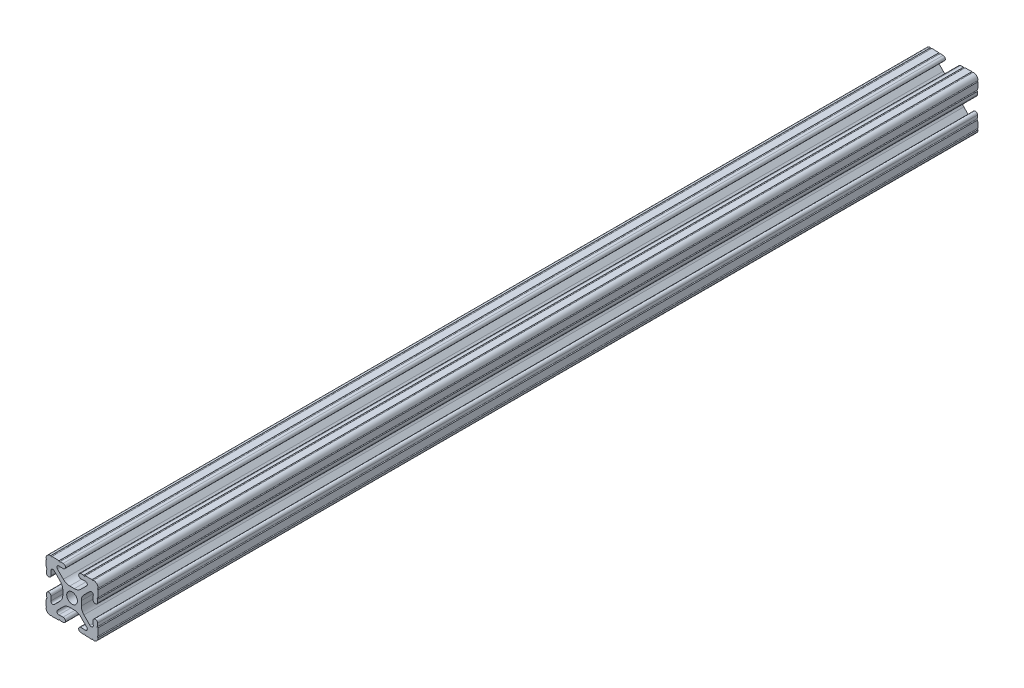
from build123d import *

# Parameters (mm, degrees)
SKETCH3_R      = 2.6035
EXTRUDE1_DEPTH = 214.55


with BuildPart() as part:
    # Sketch3 → Extrude1 (new body, symmetric)
    with BuildSketch(Plane.XY):
        with BuildLine():
            Line((-1.115277175, 4.5085), (1.115277175, 4.5085))
            ThreePointArc((1.115277175, 4.5085), (2.806584872, 4.844922018), (4.240406305, 5.80297087))
            Line((4.240406305, 5.80297087), (7.148423664, 8.710988229))
            ThreePointArc((7.148423664, 8.710988229), (7.349906316, 9.772227925), (6.436353897, 10.348636575))
            Line((6.436353897, 10.348636575), (4.381960454, 10.276895575))
            ThreePointArc((4.381960454, 10.276895575), (3.239173075, 11.342562046), (4.304839546, 12.485349424))
            Line((4.304839546, 12.485349424), (5.728246175, 12.535055879))
            ThreePointArc((5.728246175, 12.535055879), (6.054756855, 12.230579745), (6.35923299, 12.557090424))
            Line((6.35923299, 12.557090424), (9.782092278, 12.676619304))
            ThreePointArc((9.782092278, 12.676619304), (10.108602958, 12.37214317), (10.413079092, 12.69865385))
            ThreePointArc((10.413079092, 12.69865385), (12.052764565, 12.052764565), (12.69865385, 10.413079092))
            ThreePointArc((12.69865385, 10.413079092), (12.37214317, 10.108602958), (12.676619304, 9.782092278))
            Line((12.676619304, 9.782092278), (12.557090424, 6.35923299))
            ThreePointArc((12.557090424, 6.35923299), (12.230579745, 6.054756855), (12.535055879, 5.728246175))
            Line((12.535055879, 5.728246175), (12.485349424, 4.304839546))
            ThreePointArc((12.485349424, 4.304839546), (11.342562046, 3.239173075), (10.276895575, 4.381960454))
            Line((10.276895575, 4.381960454), (10.348636575, 6.436353897))
            ThreePointArc((10.348636575, 6.436353897), (9.772227925, 7.349906316), (8.710988229, 7.148423664))
            Line((8.710988229, 7.148423664), (5.80297087, 4.240406305))
            ThreePointArc((5.80297087, 4.240406305), (4.844922018, 2.806584872), (4.5085, 1.115277175))
            Line((4.5085, 1.115277175), (4.5085, -1.115277175))
            ThreePointArc((4.5085, -1.115277175), (4.844922018, -2.806584872), (5.80297087, -4.240406305))
            Line((5.80297087, -4.240406305), (8.710988229, -7.148423664))
            ThreePointArc((8.710988229, -7.148423664), (9.772227925, -7.349906316), (10.348636575, -6.436353897))
            Line((10.348636575, -6.436353897), (10.276895575, -4.381960454))
            ThreePointArc((10.276895575, -4.381960454), (11.342562046, -3.239173075), (12.485349424, -4.304839546))
            Line((12.485349424, -4.304839546), (12.535055879, -5.728246175))
            ThreePointArc((12.535055879, -5.728246175), (12.230579745, -6.054756855), (12.557090424, -6.35923299))
            Line((12.557090424, -6.35923299), (12.676619304, -9.782092278))
            ThreePointArc((12.676619304, -9.782092278), (12.37214317, -10.108602958), (12.69865385, -10.413079092))
            ThreePointArc((12.69865385, -10.413079092), (12.052764565, -12.052764565), (10.413079092, -12.69865385))
            ThreePointArc((10.413079092, -12.69865385), (10.108602958, -12.37214317), (9.782092278, -12.676619304))
            Line((9.782092278, -12.676619304), (6.35923299, -12.557090424))
            ThreePointArc((6.35923299, -12.557090424), (6.054756855, -12.230579745), (5.728246175, -12.535055879))
            Line((5.728246175, -12.535055879), (4.304839546, -12.485349424))
            ThreePointArc((4.304839546, -12.485349424), (3.239173075, -11.342562046), (4.381960454, -10.276895575))
            Line((4.381960454, -10.276895575), (6.436353897, -10.348636575))
            ThreePointArc((6.436353897, -10.348636575), (7.349906316, -9.772227925), (7.148423664, -8.710988229))
            Line((7.148423664, -8.710988229), (4.240406305, -5.80297087))
            ThreePointArc((4.240406305, -5.80297087), (2.806584872, -4.844922018), (1.115277175, -4.5085))
            Line((1.115277175, -4.5085), (-1.115277175, -4.5085))
            ThreePointArc((-1.115277175, -4.5085), (-2.806584872, -4.844922018), (-4.240406305, -5.80297087))
            Line((-4.240406305, -5.80297087), (-7.148423664, -8.710988229))
            ThreePointArc((-7.148423664, -8.710988229), (-7.349906316, -9.772227925), (-6.436353897, -10.348636575))
            Line((-6.436353897, -10.348636575), (-4.381960454, -10.276895575))
            ThreePointArc((-4.381960454, -10.276895575), (-3.239173075, -11.342562046), (-4.304839546, -12.485349424))
            Line((-4.304839546, -12.485349424), (-5.728246175, -12.535055879))
            ThreePointArc((-5.728246175, -12.535055879), (-6.054756855, -12.230579745), (-6.35923299, -12.557090424))
            Line((-6.35923299, -12.557090424), (-9.782092278, -12.676619304))
            ThreePointArc((-9.782092278, -12.676619304), (-10.108602958, -12.37214317), (-10.413079092, -12.69865385))
            ThreePointArc((-10.413079092, -12.69865385), (-12.052764565, -12.052764565), (-12.69865385, -10.413079092))
            ThreePointArc((-12.69865385, -10.413079092), (-12.37214317, -10.108602958), (-12.676619304, -9.782092278))
            Line((-12.676619304, -9.782092278), (-12.557090424, -6.35923299))
            ThreePointArc((-12.557090424, -6.35923299), (-12.230579745, -6.054756855), (-12.535055879, -5.728246175))
            Line((-12.535055879, -5.728246175), (-12.485349424, -4.304839546))
            ThreePointArc((-12.485349424, -4.304839546), (-11.342562046, -3.239173075), (-10.276895575, -4.381960454))
            Line((-10.276895575, -4.381960454), (-10.348636575, -6.436353897))
            ThreePointArc((-10.348636575, -6.436353897), (-9.772227925, -7.349906316), (-8.710988229, -7.148423664))
            Line((-8.710988229, -7.148423664), (-5.80297087, -4.240406305))
            ThreePointArc((-5.80297087, -4.240406305), (-4.844922018, -2.806584872), (-4.5085, -1.115277175))
            Line((-4.5085, -1.115277175), (-4.5085, 1.115277175))
            ThreePointArc((-4.5085, 1.115277175), (-4.844922018, 2.806584872), (-5.80297087, 4.240406305))
            Line((-5.80297087, 4.240406305), (-8.710988229, 7.148423664))
            ThreePointArc((-8.710988229, 7.148423664), (-9.772227925, 7.349906316), (-10.348636575, 6.436353897))
            Line((-10.348636575, 6.436353897), (-10.276895575, 4.381960454))
            ThreePointArc((-10.276895575, 4.381960454), (-11.342562046, 3.239173075), (-12.485349424, 4.304839546))
            Line((-12.485349424, 4.304839546), (-12.535055879, 5.728246175))
            ThreePointArc((-12.535055879, 5.728246175), (-12.230579745, 6.054756855), (-12.557090424, 6.35923299))
            Line((-12.557090424, 6.35923299), (-12.676619304, 9.782092278))
            ThreePointArc((-12.676619304, 9.782092278), (-12.37214317, 10.108602958), (-12.69865385, 10.413079092))
            ThreePointArc((-12.69865385, 10.413079092), (-12.052764565, 12.052764565), (-10.413079092, 12.69865385))
            ThreePointArc((-10.413079092, 12.69865385), (-10.108602958, 12.37214317), (-9.782092278, 12.676619304))
            Line((-9.782092278, 12.676619304), (-6.35923299, 12.557090424))
            ThreePointArc((-6.35923299, 12.557090424), (-6.054756855, 12.230579745), (-5.728246175, 12.535055879))
            Line((-5.728246175, 12.535055879), (-4.304839546, 12.485349424))
            ThreePointArc((-4.304839546, 12.485349424), (-3.239173075, 11.342562046), (-4.381960454, 10.276895575))
            Line((-4.381960454, 10.276895575), (-6.436353897, 10.348636575))
            ThreePointArc((-6.436353897, 10.348636575), (-7.349906316, 9.772227925), (-7.148423664, 8.710988229))
            Line((-7.148423664, 8.710988229), (-4.240406305, 5.80297087))
            ThreePointArc((-4.240406305, 5.80297087), (-2.806584872, 4.844922018), (-1.115277175, 4.5085))
        make_face()
        Circle(SKETCH3_R, mode=Mode.SUBTRACT)
    extrude(amount=EXTRUDE1_DEPTH, both=True)


solid = part.part
